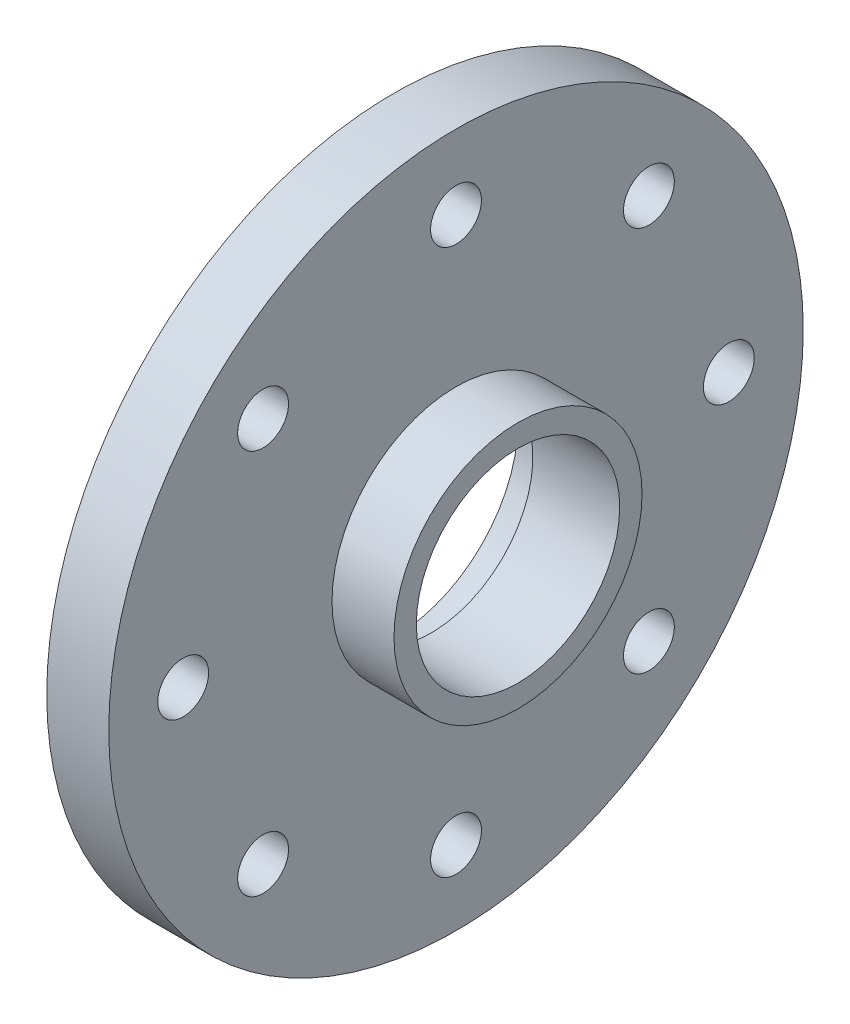
from build123d import *

# Parameters (mm, degrees)
SKETCH1_R                = 14
SKETCH1_R_2              = 4.1
BOSS_EXTRUDE1_DEPTH      = 2.5
SKETCH2_R                = 5
SKETCH2_R_2              = 4.1
BOSS_EXTRUDE2_DEPTH      = 2.5
M2_5X0_45_TAPPED_HOLE1_D = 2.05
SKETCH7_R                = 5
CUT_EXTRUDE1_DEPTH       = 1.5


with BuildPart() as part:
    # Sketch1 → Boss-Extrude1 (new body)
    with BuildSketch(Plane(origin=(0, 0, 0), x_dir=(0, 0, -1), z_dir=(1, 0, 0))):
        Circle(SKETCH1_R)
        Circle(SKETCH1_R_2, mode=Mode.SUBTRACT)
    extrude(amount=BOSS_EXTRUDE1_DEPTH)

    # Sketch2 → Boss-Extrude2 (add)
    with BuildSketch(Plane(origin=(2.5, 0, 0), x_dir=(0, 0, -1), z_dir=(1, 0, 0))):
        Circle(SKETCH2_R)
        Circle(SKETCH2_R_2, mode=Mode.SUBTRACT)
    extrude(amount=BOSS_EXTRUDE2_DEPTH)

    # M2.5x0.45 Tapped Hole1 (through all)
    with Locations(Plane(origin=(5, 0, 0), x_dir=(0, 0, -1), z_dir=(1, 0, 0))):
        with Locations((0, 11), (7.778174593, 7.778174593), (11, 0), (7.778174593, -7.778174593), (0, -11), (-7.778174593, -7.778174593), (-11, 0), (-7.778174593, 7.778174593), (0, 0)):
            Hole(M2_5X0_45_TAPPED_HOLE1_D / 2)

    # Sketch7 → Cut-Extrude1 (cut)
    with BuildSketch(Plane.ZY):
        Circle(SKETCH7_R)
    extrude(amount=-CUT_EXTRUDE1_DEPTH, mode=Mode.SUBTRACT)


solid = part.part
